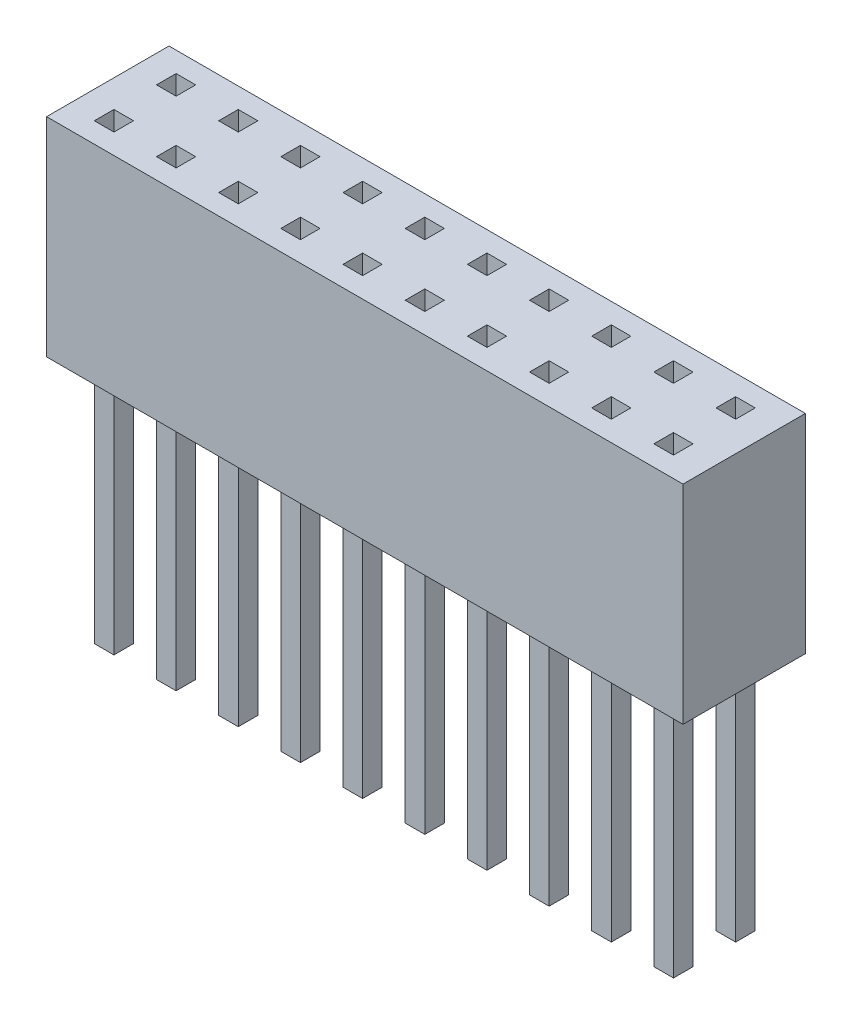
from build123d import *

# Parameters (mm, degrees)
SKIZZE1_W                       = 26
SKIZZE1_H                       = 5
AUFSATZ_LINEAR_AUSTRAGEN1_DEPTH = 8.5
SKIZZE2_W                       = 0.8
SKIZZE2_H                       = 0.8
AUFSATZ_LINEAR_AUSTRAGEN2_DEPTH = 10
SKIZZE3_W                       = 0.8
SKIZZE3_H                       = 0.8
SCHNITT_LINEAR_AUSTRAGEN1_DEPTH = 7
LINEARES_MUSTER1_COUNT          = 10
LINEARES_MUSTER1_PITCH          = 2.54
LINEARES_MUSTER1_COUNT_DIR2     = 2
LINEARES_MUSTER1_PITCH_DIR2     = 2.54


with BuildPart() as part:
    # Skizze1 → Aufsatz-Linear austragen1 (new body)
    with BuildSketch(Plane(origin=(0, 0, 0), x_dir=(1, 0, 0), z_dir=(0, 1, 0))):
        Rectangle(SKIZZE1_W, SKIZZE1_H)
    extrude(amount=AUFSATZ_LINEAR_AUSTRAGEN1_DEPTH)

    # Skizze2 → Aufsatz-Linear austragen2 (add)
    with BuildSketch(Plane(origin=(0, 0, 0), x_dir=(1, 0, 0), z_dir=(0, 1, 0))):
        with Locations((-11.48, -1.27)):
            Rectangle(SKIZZE2_W, SKIZZE2_H)
    aufsatz_linear_austragen2 = extrude(amount=-AUFSATZ_LINEAR_AUSTRAGEN2_DEPTH)

    # Skizze3 → Schnitt-Linear austragen1 (cut)
    with BuildSketch(Plane(origin=(0, 8.5, 0), x_dir=(1, 0, 0), z_dir=(0, 1, 0))):
        with Locations((-11.48, -1.27)):
            Rectangle(SKIZZE3_W, SKIZZE3_H)
    schnitt_linear_austragen1 = extrude(amount=-SCHNITT_LINEAR_AUSTRAGEN1_DEPTH, mode=Mode.SUBTRACT)

    # Lineares Muster1: Aufsatz-Linear austragen2, Schnitt-Linear austragen1 10 × 2
    with Locations(*[(i * LINEARES_MUSTER1_PITCH, 0, -j * LINEARES_MUSTER1_PITCH_DIR2) for i in range(LINEARES_MUSTER1_COUNT) for j in range(LINEARES_MUSTER1_COUNT_DIR2) if (i, j) != (0, 0)]):
        add(aufsatz_linear_austragen2)
        add(schnitt_linear_austragen1, mode=Mode.SUBTRACT)


solid = part.part
